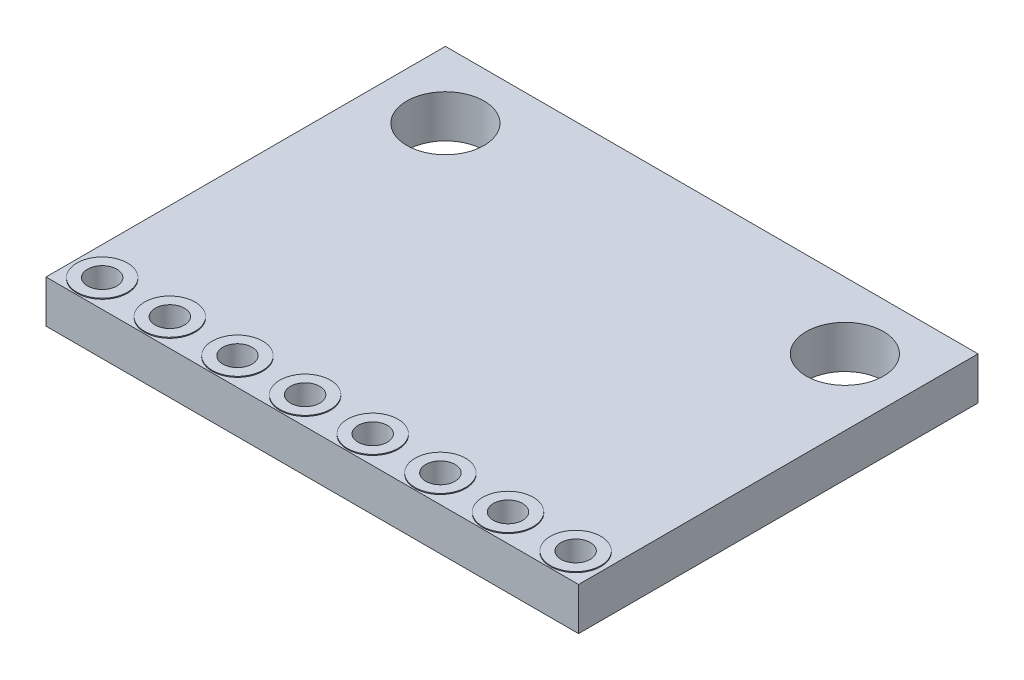
from build123d import *

# Parameters (mm, degrees)
ESBO_O1_W                = 20
ESBO_O1_H                = 15
ESBO_O1_R                = 1.45
ESBO_O1_R_2              = 0.55
RESSALTO_EXTRUS_O1_DEPTH = 1.6
ESBO_O2_R                = 0.95
ESBO_O2_R_2              = 0.55
RESSALTO_EXTRUS_O2_DEPTH = 0.035
ESBO_O3_R                = 0.95
ESBO_O3_R_2              = 0.55
RESSALTO_EXTRUS_O3_DEPTH = 0.035


with BuildPart() as part:
    # Esboço1 → Ressalto-extrusão1 (new body)
    with BuildSketch(Plane(origin=(0, 0, 0), x_dir=(1, 0, 0), z_dir=(0, 1, 0))):
        Rectangle(ESBO_O1_W, ESBO_O1_H)
        with Locations((-7.5, 5)):
            Circle(ESBO_O1_R, mode=Mode.SUBTRACT)
        with Locations((7.5, 5)):
            Circle(ESBO_O1_R, mode=Mode.SUBTRACT)
        with Locations((-1.27, -6.5)):
            Circle(ESBO_O1_R_2, mode=Mode.SUBTRACT)
        with Locations((-3.81, -6.5)):
            Circle(ESBO_O1_R_2, mode=Mode.SUBTRACT)
        with Locations((-6.35, -6.5)):
            Circle(ESBO_O1_R_2, mode=Mode.SUBTRACT)
        with Locations((-8.89, -6.5)):
            Circle(ESBO_O1_R_2, mode=Mode.SUBTRACT)
        with Locations((1.27, -6.5)):
            Circle(ESBO_O1_R_2, mode=Mode.SUBTRACT)
        with Locations((3.81, -6.5)):
            Circle(ESBO_O1_R_2, mode=Mode.SUBTRACT)
        with Locations((6.35, -6.5)):
            Circle(ESBO_O1_R_2, mode=Mode.SUBTRACT)
        with Locations((8.89, -6.5)):
            Circle(ESBO_O1_R_2, mode=Mode.SUBTRACT)
    extrude(amount=RESSALTO_EXTRUS_O1_DEPTH)

    # Esboço2 → Ressalto-extrusão2 (add)
    with BuildSketch(Plane(origin=(0, 1.6, 0), x_dir=(1, 0, 0), z_dir=(0, 1, 0))):
        with Locations((-6.35, -6.5)):
            Circle(ESBO_O2_R)
        with Locations((-6.35, -6.5)):
            Circle(ESBO_O2_R_2, mode=Mode.SUBTRACT)
        with Locations((-8.89, -6.5)):
            Circle(ESBO_O2_R)
        with Locations((-8.89, -6.5)):
            Circle(ESBO_O2_R_2, mode=Mode.SUBTRACT)
        with Locations((-3.81, -6.5)):
            Circle(ESBO_O2_R)
        with Locations((-3.81, -6.5)):
            Circle(ESBO_O2_R_2, mode=Mode.SUBTRACT)
        with Locations((-1.27, -6.5)):
            Circle(ESBO_O2_R)
        with Locations((-1.27, -6.5)):
            Circle(ESBO_O2_R_2, mode=Mode.SUBTRACT)
        with Locations((1.27, -6.5)):
            Circle(ESBO_O2_R)
        with Locations((1.27, -6.5)):
            Circle(ESBO_O2_R_2, mode=Mode.SUBTRACT)
        with Locations((3.81, -6.5)):
            Circle(ESBO_O2_R)
        with Locations((3.81, -6.5)):
            Circle(ESBO_O2_R_2, mode=Mode.SUBTRACT)
        with Locations((6.35, -6.5)):
            Circle(ESBO_O2_R)
        with Locations((6.35, -6.5)):
            Circle(ESBO_O2_R_2, mode=Mode.SUBTRACT)
        with Locations((8.89, -6.5)):
            Circle(ESBO_O2_R)
        with Locations((8.89, -6.5)):
            Circle(ESBO_O2_R_2, mode=Mode.SUBTRACT)
    extrude(amount=RESSALTO_EXTRUS_O2_DEPTH)

    # Esboço3 → Ressalto-extrusão3 (add)
    with BuildSketch(Plane.XZ):
        with Locations((8.89, 6.5)):
            Circle(ESBO_O3_R)
        with Locations((8.89, 6.5)):
            Circle(ESBO_O3_R_2, mode=Mode.SUBTRACT)
        with Locations((6.35, 6.5)):
            Circle(ESBO_O3_R)
        with Locations((6.35, 6.5)):
            Circle(ESBO_O3_R_2, mode=Mode.SUBTRACT)
        with Locations((3.81, 6.5)):
            Circle(ESBO_O3_R)
        with Locations((3.81, 6.5)):
            Circle(ESBO_O3_R_2, mode=Mode.SUBTRACT)
        with Locations((1.27, 6.5)):
            Circle(ESBO_O3_R)
        with Locations((1.27, 6.5)):
            Circle(ESBO_O3_R_2, mode=Mode.SUBTRACT)
        with Locations((-1.27, 6.5)):
            Circle(ESBO_O3_R)
        with Locations((-1.27, 6.5)):
            Circle(ESBO_O3_R_2, mode=Mode.SUBTRACT)
        with Locations((-3.81, 6.5)):
            Circle(ESBO_O3_R)
        with Locations((-3.81, 6.5)):
            Circle(ESBO_O3_R_2, mode=Mode.SUBTRACT)
        with Locations((-6.35, 6.5)):
            Circle(ESBO_O3_R)
        with Locations((-6.35, 6.5)):
            Circle(ESBO_O3_R_2, mode=Mode.SUBTRACT)
        with Locations((-8.89, 6.5)):
            Circle(ESBO_O3_R)
        with Locations((-8.89, 6.5)):
            Circle(ESBO_O3_R_2, mode=Mode.SUBTRACT)
    extrude(amount=RESSALTO_EXTRUS_O3_DEPTH)


solid = part.part
